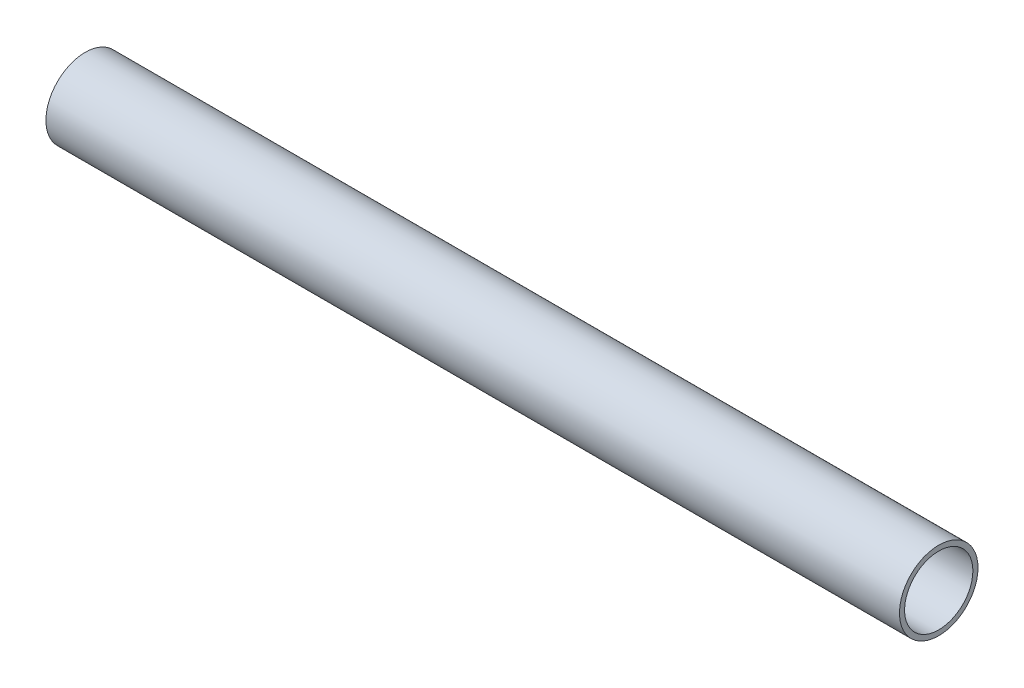
from build123d import *

# Parameters (mm, degrees)
SKETCH1_R           = 11.5
SKETCH1_R_2         = 10
BOSS_EXTRUDE2_DEPTH = 250


with BuildPart() as part:
    # Sketch1 → Boss-Extrude2 (new body)
    with BuildSketch(Plane(origin=(0, 0, 0), x_dir=(0, 0, -1), z_dir=(1, 0, 0))):
        Circle(SKETCH1_R)
        Circle(SKETCH1_R_2, mode=Mode.SUBTRACT)
    extrude(amount=BOSS_EXTRUDE2_DEPTH)


solid = part.part
